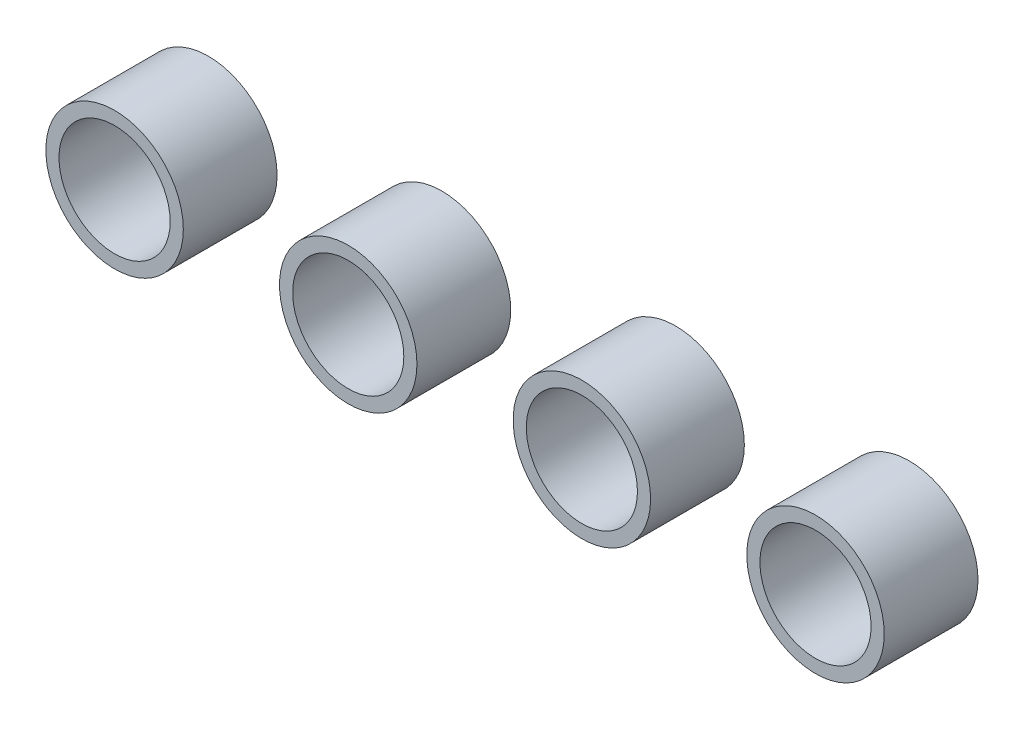
from build123d import *

# Parameters (mm, degrees)
SKETCH1_R             = 21.59
SKETCH1_R_2           = 17.4625
BOSS_EXTRUDE4_DEPTH   = 29.464
BOSS_EXTRUDE4_2_DEPTH = 29.464
BOSS_EXTRUDE4_3_DEPTH = 29.464
BOSS_EXTRUDE4_4_DEPTH = 29.464


with BuildPart() as part:
    # Sketch1 → Boss-Extrude4 (new body)
    with BuildSketch(Plane.XY):
        Circle(SKETCH1_R)
        Circle(SKETCH1_R_2, mode=Mode.SUBTRACT)
    extrude(amount=BOSS_EXTRUDE4_DEPTH)


with BuildPart() as body_2:
    # Sketch1 → Boss-Extrude4 2 (new body)
    with BuildSketch(Plane.XY):
        with Locations((73.406, 0)):
            Circle(SKETCH1_R)
        with Locations((73.406, 0)):
            Circle(SKETCH1_R_2, mode=Mode.SUBTRACT)
    extrude(amount=BOSS_EXTRUDE4_2_DEPTH)


with BuildPart() as body_3:
    # Sketch1 → Boss-Extrude4 3 (new body)
    with BuildSketch(Plane.XY):
        with Locations((146.812, 0)):
            Circle(SKETCH1_R)
        with Locations((146.812, 0)):
            Circle(SKETCH1_R_2, mode=Mode.SUBTRACT)
    extrude(amount=BOSS_EXTRUDE4_3_DEPTH)


with BuildPart() as body_4:
    # Sketch1 → Boss-Extrude4 4 (new body)
    with BuildSketch(Plane.XY):
        with Locations((220.218, 0)):
            Circle(SKETCH1_R)
        with Locations((220.218, 0)):
            Circle(SKETCH1_R_2, mode=Mode.SUBTRACT)
    extrude(amount=BOSS_EXTRUDE4_4_DEPTH)


solid = Compound([part.part, body_2.part, body_3.part, body_4.part])
